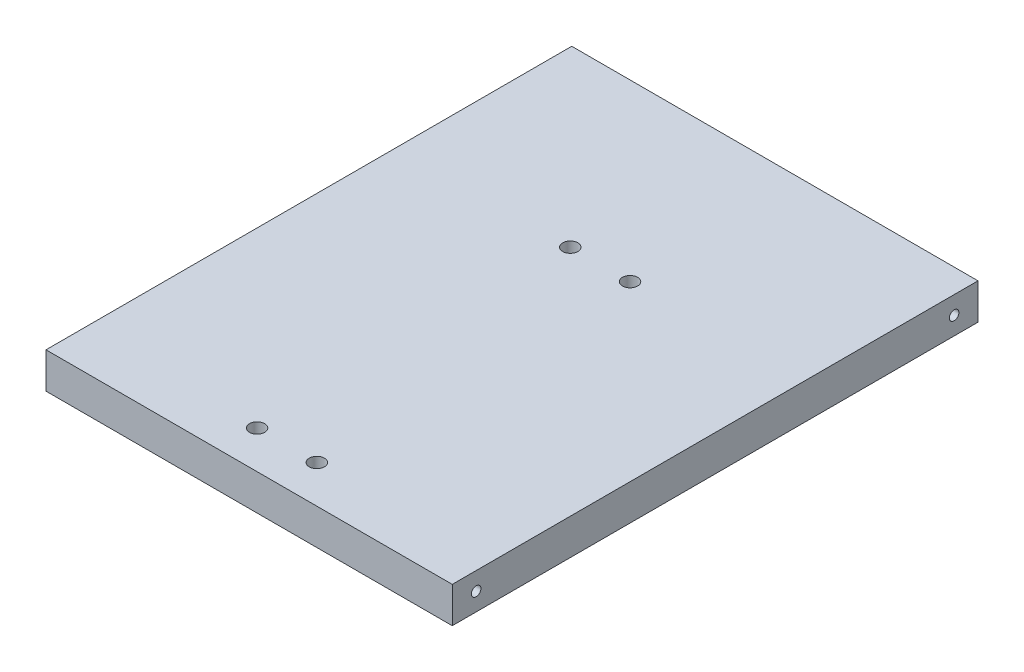
from build123d import *

# Parameters (mm, degrees)
SKETCH1_W           = 170
SKETCH1_H           = 220
BOSS_EXTRUDE1_DEPTH = 15
SKETCH2_R           = 2
CUT_EXTRUDE1_DEPTH  = 20
SKETCH3_R           = 3.175
CUT_EXTRUDE2_DEPTH  = 15


with BuildPart() as part:
    # Sketch1 → Boss-Extrude1 (new body)
    with BuildSketch(Plane(origin=(0, 0, 0), x_dir=(1, 0, 0), z_dir=(0, 1, 0))):
        with Locations((85, 110)):
            Rectangle(SKETCH1_W, SKETCH1_H)
    extrude(amount=BOSS_EXTRUDE1_DEPTH)

    # Sketch2 → Cut-Extrude1 (cut)
    with BuildSketch(Plane.ZY):
        with Locations((-10, 7.5)):
            Circle(SKETCH2_R)
        with Locations((-210, 7.5)):
            Circle(SKETCH2_R)
    cut_extrude1 = extrude(amount=-CUT_EXTRUDE1_DEPTH, mode=Mode.SUBTRACT)

    # Sketch3 → Cut-Extrude2 (cut)
    with BuildSketch(Plane(origin=(0, 15, 0), x_dir=(1, 0, 0), z_dir=(0, 1, 0))):
        with Locations((72.5, 15.821244145)):
            Circle(SKETCH3_R)
        with Locations((72.5, 146.891244145)):
            Circle(SKETCH3_R)
    cut_extrude2 = extrude(amount=-CUT_EXTRUDE2_DEPTH, mode=Mode.SUBTRACT)

    # Mirror1: Cut-Extrude1, Cut-Extrude2 across plane
    add(cut_extrude1.mirror(Plane.ZY.offset(-85)), mode=Mode.SUBTRACT)
    add(cut_extrude2.mirror(Plane.ZY.offset(-85)), mode=Mode.SUBTRACT)


solid = part.part
